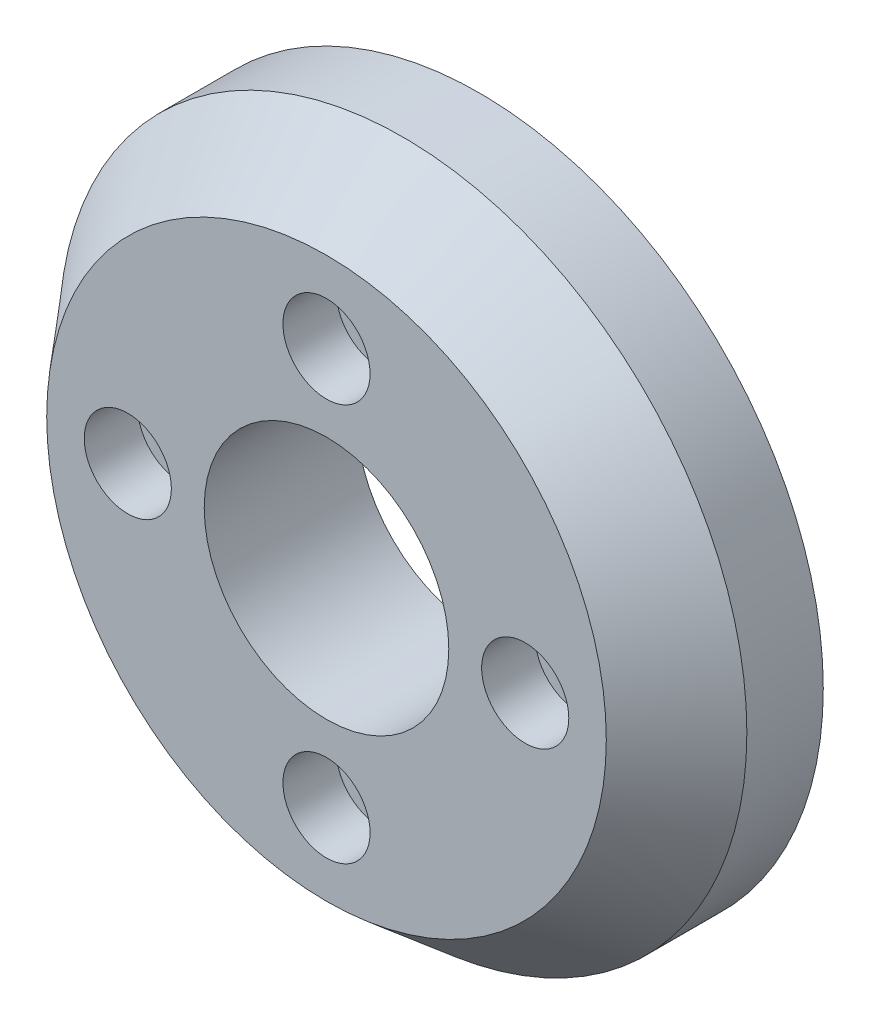
from build123d import *

# Parameters (mm, degrees)
SKETCH1_R               = 22.5
SKETCH1_R_2             = 2.85
BOSS_EXTRUDE1_DEPTH     = 10
SKETCH1_3_R             = 2.85
SKETCH1_3_R_2           = 1.6
BOSS_EXTRUDE2_DEPTH     = 6.5
CHAMFER1_SIZE           = 5
CHAMFER1_SIZE2          = 4.195498156
SKETCH2_R               = 8
CUT_EXTRUDE1_DEPTH      = 1
CUT_EXTRUDE1_DEPTH_BACK = 11


with BuildPart() as part:
    # Sketch1 → Boss-Extrude1 (new body)
    with BuildSketch(Plane(origin=(0, 0, 0), x_dir=(0, 1, 0), z_dir=(0, 0, 1))):
        Circle(SKETCH1_R)
        with Locations((-13, 0)):
            Circle(SKETCH1_R_2, mode=Mode.SUBTRACT)
        with Locations((0, -13)):
            Circle(SKETCH1_R_2, mode=Mode.SUBTRACT)
        with Locations((13, 0)):
            Circle(SKETCH1_R_2, mode=Mode.SUBTRACT)
        with Locations((0, 13)):
            Circle(SKETCH1_R_2, mode=Mode.SUBTRACT)
    extrude(amount=BOSS_EXTRUDE1_DEPTH)

    # Sketch1_3 → Boss-Extrude2 (add)
    with BuildSketch(Plane(origin=(0, 0, 0), x_dir=(0, 1, 0), z_dir=(0, 0, 1))):
        with Locations((-13, 0)):
            Circle(SKETCH1_3_R)
        with Locations((-13, 0)):
            Circle(SKETCH1_3_R_2, mode=Mode.SUBTRACT)
        with Locations((0, 13)):
            Circle(SKETCH1_3_R)
        with Locations((0, 13)):
            Circle(SKETCH1_3_R_2, mode=Mode.SUBTRACT)
        with Locations((13, 0)):
            Circle(SKETCH1_3_R)
        with Locations((13, 0)):
            Circle(SKETCH1_3_R_2, mode=Mode.SUBTRACT)
        with Locations((0, -13)):
            Circle(SKETCH1_3_R)
        with Locations((0, -13)):
            Circle(SKETCH1_3_R_2, mode=Mode.SUBTRACT)
    extrude(amount=BOSS_EXTRUDE2_DEPTH)

    # Chamfer1
    chamfer1_edges = [part.edges().sort_by_distance(p)[0] for p in [
        (0, -22.5, 10),
    ]]
    chamfer1_side = [part.faces().sort_by_distance(p)[0] for p in [
        (0, -22.5, 5),
    ]]
    chamfer(chamfer1_edges, length=CHAMFER1_SIZE, length2=CHAMFER1_SIZE2, reference=chamfer1_side[0])

    # Sketch2 → Cut-Extrude1 (cut, two sides)
    with BuildSketch(Plane.XY.offset(10)) as cut_extrude1_sk:
        Circle(SKETCH2_R)
    extrude(amount=CUT_EXTRUDE1_DEPTH, mode=Mode.SUBTRACT)
    extrude(cut_extrude1_sk.sketch, amount=-CUT_EXTRUDE1_DEPTH_BACK, mode=Mode.SUBTRACT)


solid = part.part
